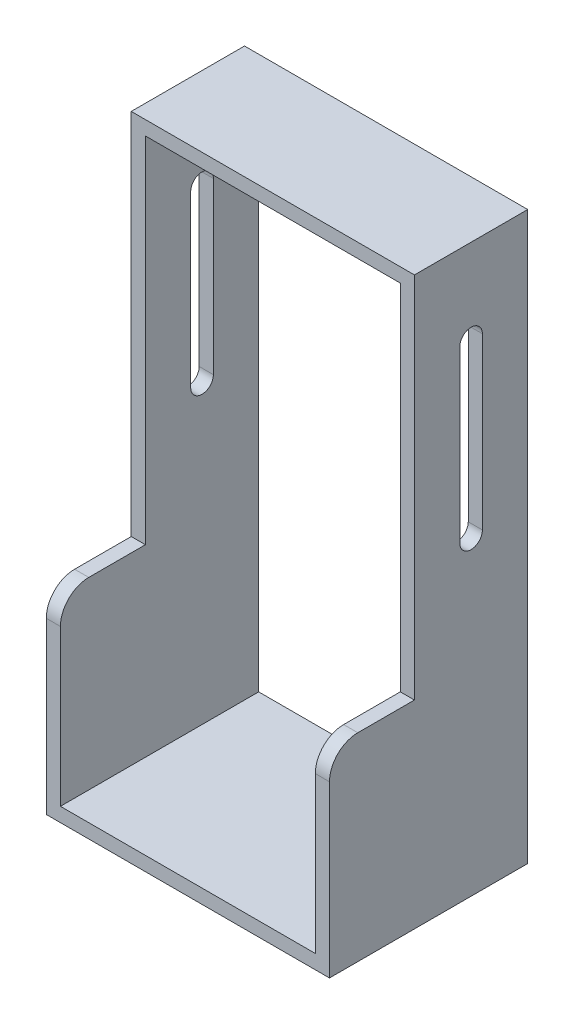
from build123d import *

# Parameters (mm, degrees)
SKETCH1_W               = 100
SKETCH1_H               = 200
SKETCH1_W_2             = 90
SKETCH1_H_2             = 190
BOSS_EXTRUDE1_DEPTH     = 70
SKETCH2_W               = 30
SKETCH2_H               = 130
CUT_EXTRUDE1_DEPTH      = 1
CUT_EXTRUDE1_DEPTH_BACK = 101
FILLET1_R               = 10
SKETCH3_R               = 2.5
BOSS_EXTRUDE2_DEPTH     = 5
CUT_EXTRUDE2_DEPTH      = 1
CUT_EXTRUDE2_DEPTH_BACK = 101


with BuildPart() as part:
    # Sketch1 → Boss-Extrude1 (new body)
    with BuildSketch(Plane.XY):
        Rectangle(SKETCH1_W, SKETCH1_H)
        Rectangle(SKETCH1_W_2, SKETCH1_H_2, mode=Mode.SUBTRACT)
    extrude(amount=BOSS_EXTRUDE1_DEPTH)

    # Sketch2 → Cut-Extrude1 (cut, two sides)
    with BuildSketch(Plane(origin=(50, 0, 0), x_dir=(0, 0, -1), z_dir=(1, 0, 0))) as cut_extrude1_sk:
        with Locations((-55, 35)):
            Rectangle(SKETCH2_W, SKETCH2_H)
    extrude(amount=CUT_EXTRUDE1_DEPTH, mode=Mode.SUBTRACT)
    extrude(cut_extrude1_sk.sketch, amount=-CUT_EXTRUDE1_DEPTH_BACK, mode=Mode.SUBTRACT)

    # Fillet1
    fillet1_edges = [part.edges().sort_by_distance(p)[0] for p in [
        (47.5, -30, 70),
        (-47.5, -30, 70),
    ]]
    fillet(fillet1_edges, radius=FILLET1_R)

    # Sketch3 → Boss-Extrude2 (add)
    with BuildSketch(Plane.XZ.offset(-95)):
        with Locations((0, 15)):
            Circle(SKETCH3_R)
    extrude(amount=BOSS_EXTRUDE2_DEPTH)

    # Sketch4 → Cut-Extrude2 (cut, two sides)
    with BuildSketch(Plane.ZY.offset(50)) as cut_extrude2_sk:
        with BuildLine():
            Line((16, 10), (16, 70))
            ThreePointArc((16, 70), (20, 74), (24, 70))
            Line((24, 70), (24, 10))
            ThreePointArc((24, 10), (20, 6), (16, 10))
        make_face()
    extrude(amount=CUT_EXTRUDE2_DEPTH, mode=Mode.SUBTRACT)
    extrude(cut_extrude2_sk.sketch, amount=-CUT_EXTRUDE2_DEPTH_BACK, mode=Mode.SUBTRACT)


solid = part.part
